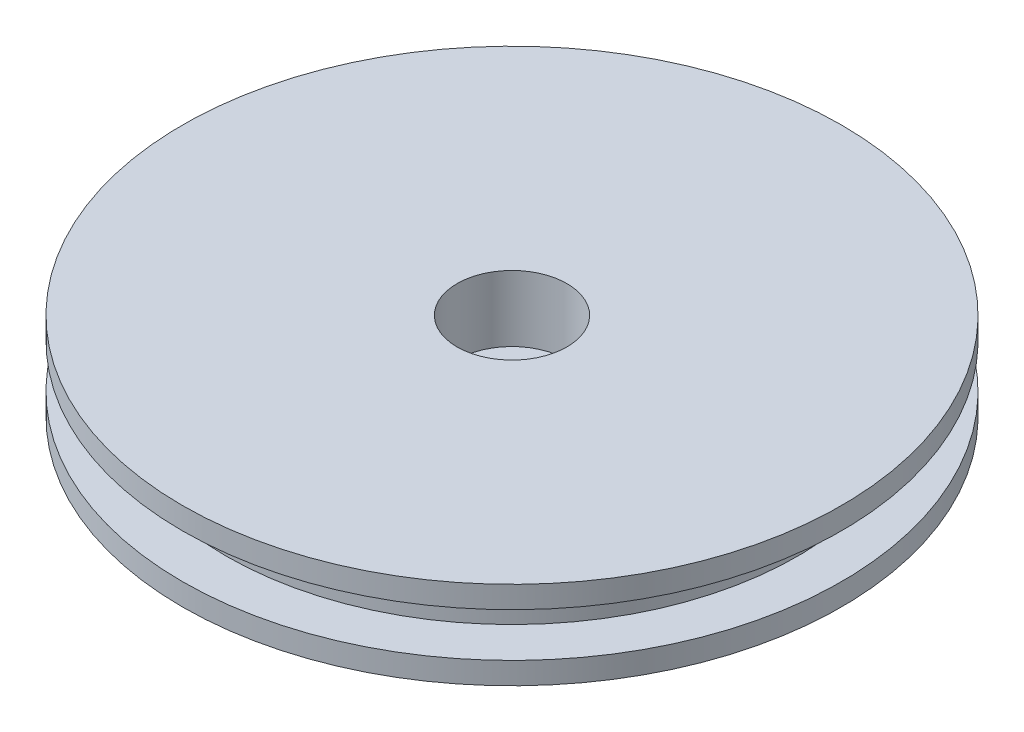
from build123d import *

# Parameters (mm, degrees)
PER_AGE1_D           = 3
PER_AGE1_CBORE_D     = 5
PER_AGE1_CBORE_DEPTH = 3


with BuildPart() as part:
    # Esquisse1 → Révolution1 (revolve)
    with BuildSketch(Plane(origin=(0, 0, 0), x_dir=(0, 0, -1), z_dir=(1, 0, 0))):
        Polygon((0, 2), (-15, 2), (-15, 1), (-13, 1), (-13, -1), (-15, -1), (-15, -2), (0, -2), align=None)
    revolve(axis=Axis((0, 2, 0), (0, -1, 0)))

    # Perçage1 (through all)
    with Locations(Plane(origin=(0, 2, 0), x_dir=(1, 0, 0), z_dir=(0, 1, 0))):
        with Locations((0, 0)):
            CounterBoreHole(PER_AGE1_D / 2, PER_AGE1_CBORE_D / 2, PER_AGE1_CBORE_DEPTH)


solid = part.part
